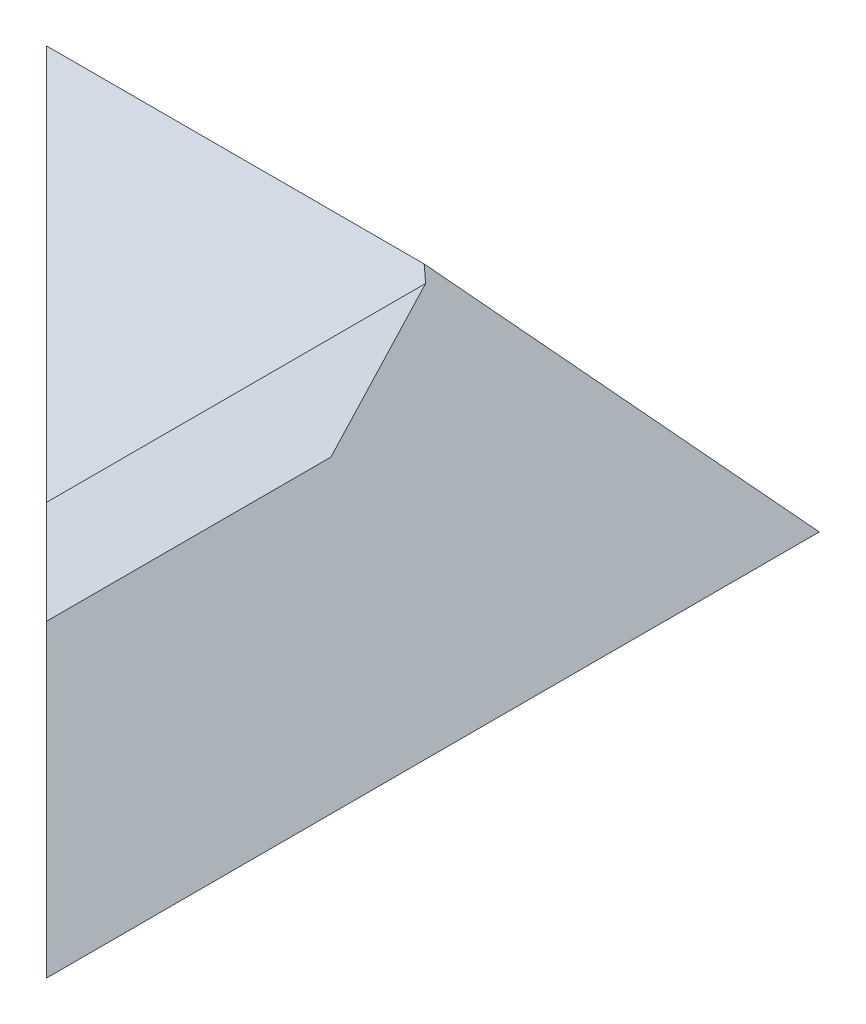
from build123d import *

# Parameters (mm, degrees)
SURFACESAB_DEPTH        = 150
SURFACESCD_DEPTH        = 80
SURFACESCD_DEPTH_BACK   = 70
CUT_EXTRUDE3_DEPTH      = 42.711375741
SURFACEE_DEPTH          = 130
CUT_EXTRUDE9_DEPTH      = 81
CUT_EXTRUDE9_DEPTH_BACK = 71
CUT_EXTRUDE10_DEPTH     = 150


with BuildPart() as part:
    # Sketch2 → SurfacesAB (new body)
    with BuildSketch(Plane(origin=(0, 0, 0), x_dir=(0, 0, -1), z_dir=(1, 0, 0))):
        Polygon((0, 0), (35, 41.711375741), (70, 0), align=None)
    extrude(amount=SURFACESAB_DEPTH)

    # Sketch3 → SurfacesCD (add, two sides)
    with BuildSketch(Plane.XY) as surfacescd_sk:
        Polygon((150, 0), (120, 30), (90, 0), align=None)
    extrude(amount=SURFACESCD_DEPTH)
    extrude(surfacescd_sk.sketch, amount=-SURFACESCD_DEPTH_BACK)

    # Sketch6 → Cut-Extrude3 (cut, through all)
    with BuildSketch(Plane(origin=(0, 0, 0), x_dir=(1, 0, 0), z_dir=(0, 1, 0))):
        Polygon((0, 70), (150, -80), (0, -80), align=None)
    extrude(amount=CUT_EXTRUDE3_DEPTH, mode=Mode.SUBTRACT)

    # Sketch13 → SurfaceE (add)
    with BuildSketch(Plane(origin=(150, 0, 80), x_dir=(-0.707106781, 0, 0.707106781), z_dir=(-0.707106781, 0, -0.707106781))):
        Polygon((0, 0), (-14.142135624, 0), (-79.799705645, 50.488741568), (-80.104771591, 61.598214949), align=None)
    extrude(amount=SURFACEE_DEPTH)

    # Sketch10 → Cut-Extrude9 (cut, two sides)
    with BuildSketch(Plane.XY) as cut_extrude9_sk:
        Polygon((150, 0), (83.43213667, 66.56786333), (150, 66.56786333), (213.23579194, 66.56786333), (213.23579194, 0), align=None)
    extrude(amount=CUT_EXTRUDE9_DEPTH, mode=Mode.SUBTRACT)
    extrude(cut_extrude9_sk.sketch, amount=-CUT_EXTRUDE9_DEPTH_BACK, mode=Mode.SUBTRACT)

    # Sketch4 → Cut-Extrude10 (cut)
    with BuildSketch(Plane(origin=(150, 0, 0), x_dir=(0, 0, -1), z_dir=(1, 0, 0))):
        Polygon((70, 0), (18.686100405, 61.153524192), (70, 61.153524192), align=None)
    extrude(amount=-CUT_EXTRUDE10_DEPTH, mode=Mode.SUBTRACT)


solid = part.part
